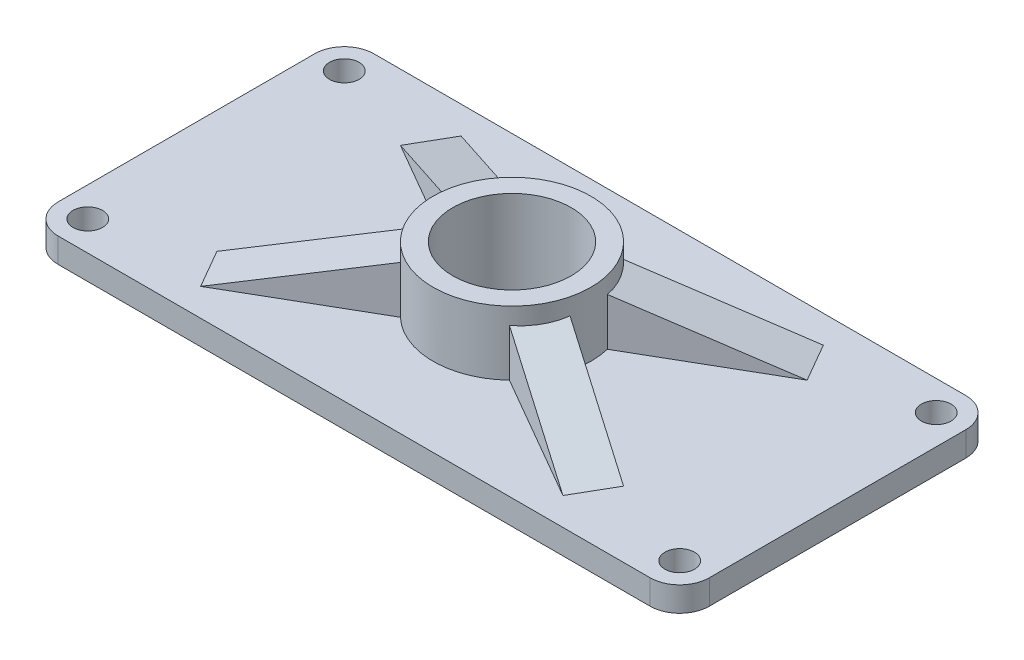
from build123d import *

# Parameters (mm, degrees)
SKETCH1_R           = 12
SKETCH1_R_2         = 3
BOSS_EXTRUDE2_DEPTH = 5
SKETCH2_R           = 16
SKETCH2_R_2         = 12
BOSS_EXTRUDE3_DEPTH = 13
BOSS_EXTRUDE9_DEPTH = 4.5


with BuildPart() as part:
    # Sketch1 → Boss-Extrude2 (new body)
    with BuildSketch(Plane(origin=(0, 0, 0), x_dir=(1, 0, 0), z_dir=(0, 1, 0))):
        with BuildLine():
            Line((-60, -32), (60, -32))
            ThreePointArc((60, -32), (64.242640687, -30.242640687), (66, -26))
            Line((66, -26), (66, 26))
            ThreePointArc((66, 26), (64.242640687, 30.242640687), (60, 32))
            Line((60, 32), (-60, 32))
            ThreePointArc((-60, 32), (-64.242640687, 30.242640687), (-66, 26))
            Line((-66, 26), (-66, -26))
            ThreePointArc((-66, -26), (-64.242640687, -30.242640687), (-60, -32))
        make_face()
        Circle(SKETCH1_R, mode=Mode.SUBTRACT)
        with Locations((60, 26)):
            Circle(SKETCH1_R_2, mode=Mode.SUBTRACT)
        with Locations((60, -26)):
            Circle(SKETCH1_R_2, mode=Mode.SUBTRACT)
        with Locations((-60, -26)):
            Circle(SKETCH1_R_2, mode=Mode.SUBTRACT)
        with Locations((-60, 26)):
            Circle(SKETCH1_R_2, mode=Mode.SUBTRACT)
    extrude(amount=BOSS_EXTRUDE2_DEPTH)

    # Sketch2 → Boss-Extrude3 (add)
    with BuildSketch(Plane(origin=(0, 5, 0), x_dir=(1, 0, 0), z_dir=(0, 1, 0))):
        Circle(SKETCH2_R)
        Circle(SKETCH2_R_2, mode=Mode.SUBTRACT)
    extrude(amount=BOSS_EXTRUDE3_DEPTH)

    # Sketch4 → Boss-Extrude9 (add, symmetric)
    with BuildSketch(Plane(origin=(0, 0, 0), x_dir=(0.866025404, 0, 0.5), z_dir=(-0.5, 0, 0.866025404))):
        Polygon((-12, 15.722349976), (-45, 5), (-12, 5), align=None)
        Polygon((12, 15.722349976), (12, 5), (45, 5), align=None)
    boss_extrude9 = extrude(amount=BOSS_EXTRUDE9_DEPTH, both=True)

    # Mirror1: Boss-Extrude9 across plane
    add(boss_extrude9.mirror(Plane.XY))


solid = part.part
